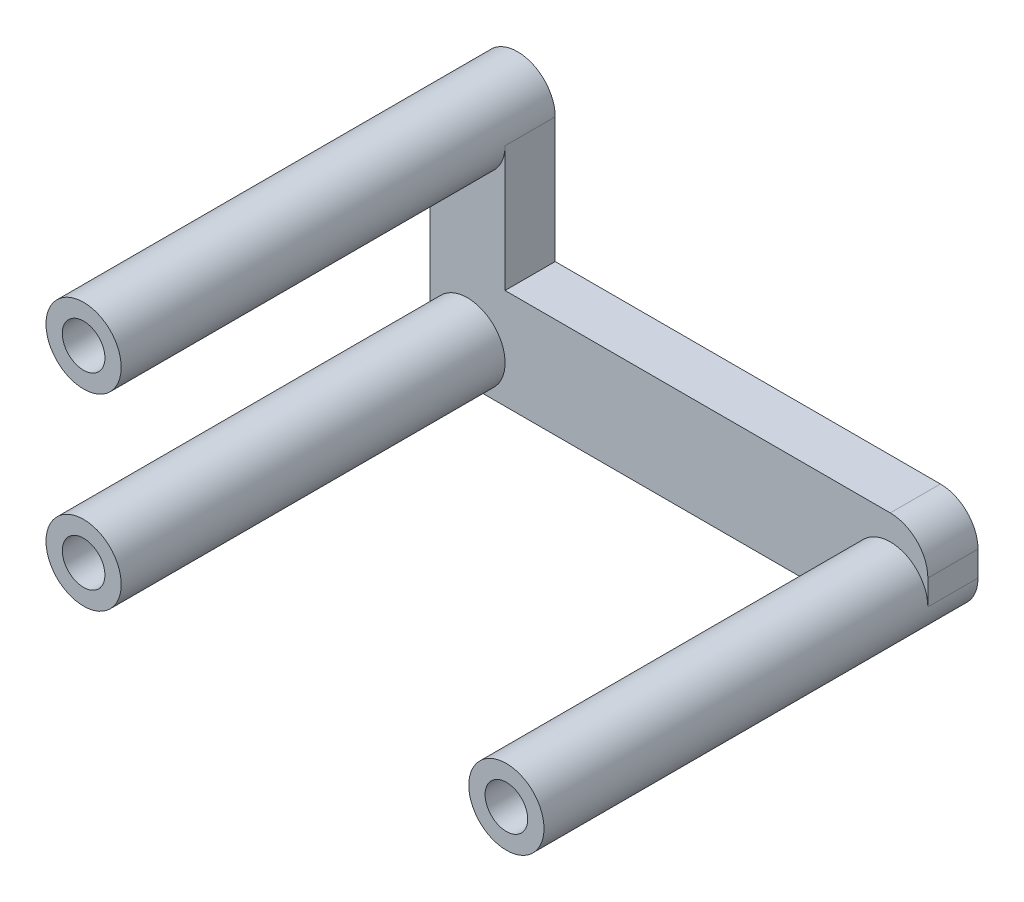
from build123d import *
from build123d.topology import SkipClean

# Parameters (mm, degrees)
SKIZZE1_R                         = 3
AUFSATZ_LINEAR_AUSTRAGEN1_DEPTH   = 4
AUFSATZ_LINEAR_AUSTRAGEN1_2_DEPTH = 4
AUFSATZ_LINEAR_START              = 1
SKIZZE2_W                         = 39.730311682
SKIZZE2_H                         = 6
AUFSATZ_LINEAR_AUSTRAGEN2_DEPTH   = 4
SKIZZE3_R                         = 3
AUFSATZ_LINEAR_AUSTRAGEN3_DEPTH   = 34.6252
SCHNITT_LINEAR_AUSTRAGEN1_DEPTH   = 56.942794256
SKIZZE11_W                        = 6
SKIZZE11_H                        = 15
AUFSATZ_LINEAR_AUSTRAGEN8_DEPTH   = 4
SKIZZE12_R                        = 1.7
SCHNITT_LINEAR_AUSTRAGEN6_DEPTH   = 4
SKIZZE14_W                        = 25.08
SKIZZE14_H                        = 6
SCHNITT_LINEAR_AUSTRAGEN8_DEPTH   = 59.228840184
SKIZZE15_W                        = 33.730311682
SKIZZE15_H                        = 5
AUFSATZ_LINEAR_AUSTRAGEN9_DEPTH   = 4
SKIZZE17_R                        = 1.7
SCHNITT_LINEAR_AUSTRAGEN9_DEPTH   = 2
VERRUNDUNG1_R                     = 3


with BuildPart() as part:
    # Skizze1 → Aufsatz-Linear austragen1 (new body)
    with BuildSketch(Plane.XY):
        with Locations((-15.621, 18.161)):
            Circle(SKIZZE1_R)
    extrude(amount=AUFSATZ_LINEAR_AUSTRAGEN1_DEPTH)



with BuildPart() as body_2:
    # Skizze1 → Aufsatz-Linear austragen1 2 (new body)
    with BuildSketch(Plane.XY):
        with Locations(Location((3.459, 18.161, 0), (0, 0, 180))):
            Circle(SKIZZE1_R)
    extrude(amount=AUFSATZ_LINEAR_AUSTRAGEN1_2_DEPTH)


with BuildPart() as part_1:
    add(part.part)

    add(body_2.part)  # Aufsatz-Linear austragen2 merges body 2
    # Skizze2 → Aufsatz-Linear austragen2 (add)
    with BuildSketch(Plane.XY.offset(AUFSATZ_LINEAR_START)):
        with Locations((-9.868250172, 18.161)):
            Rectangle(SKIZZE2_W, SKIZZE2_H)
    extrude(amount=AUFSATZ_LINEAR_AUSTRAGEN2_DEPTH)

    # Skizze3 → Aufsatz-Linear austragen3 (add)
    with BuildSketch(Plane.XY.offset(1)):
        with Locations(Location((-26.733406013, 18.161, 0), (0, 0, 90))):
            Circle(SKIZZE3_R)
        with Locations(Location((6.996905669, 18.161, 0), (0, 0, 90))):
            Circle(SKIZZE3_R)
        with Locations(Location((-26.733406013, 33.161, 0), (0, 0, 180))):
            Circle(SKIZZE3_R)
    extrude(amount=AUFSATZ_LINEAR_AUSTRAGEN3_DEPTH)


with BuildPart() as aufsatz_linear_austragen3_piece_1:
    # of the separate pieces the step leaves, piece 1, a body of its own (aufsatz_linear_austragen3_pieces)
    add(part_1.part.solids().sort_by_distance((-12.621, 18.161, 0))[0])

    # Skizze5 → Schnitt-Linear austragen1 (cut, through all)
    with SkipClean():  # the faces are left unmerged after this step: merging them gives an invalid solid
        with BuildSketch(Plane.XY.offset(5)):
            with BuildLine():
                Line((-26.733406013, 21.161), (-36.757848336, 21.161))
                Line((-36.757848336, 21.161), (-36.757848336, 15.161))
                Line((-36.757848336, 15.161), (-26.733406013, 15.161))
                ThreePointArc((-26.733406013, 15.161), (-29.733406013, 18.161), (-26.733406013, 21.161))
            make_face()
            with BuildLine():
                Line((17.021347992, 15.161), (6.996905669, 15.161))
                ThreePointArc((6.996905669, 15.161), (9.996905669, 18.161), (6.996905669, 21.161))
                Line((6.996905669, 21.161), (17.021347992, 21.161))
                Line((17.021347992, 21.161), (17.021347992, 15.161))
            make_face()
        extrude(amount=-SCHNITT_LINEAR_AUSTRAGEN1_DEPTH, mode=Mode.SUBTRACT)



with BuildPart() as aufsatz_linear_austragen3_piece_2:
    # of the separate pieces the step leaves, piece 2, a body of its own (aufsatz_linear_austragen3_pieces)
    add(part_1.part.solids().sort_by_distance((-29.733406013, 33.161, 1))[0])


with BuildPart() as aufsatz_linear_austragen3_piece_1_1:
    with SkipClean():  # the faces are left unmerged after this step: merging them gives an invalid solid
        add(aufsatz_linear_austragen3_piece_1.part)

        add(aufsatz_linear_austragen3_piece_2.part)  # Aufsatz-Linear austragen8 merges Aufsatz-Linear austragen3 piece 2
        # Skizze11 → Aufsatz-Linear austragen8 (add)
        with BuildSketch(Plane.XY.offset(5)):
            with Locations((-26.733406013, 25.661)):
                Rectangle(SKIZZE11_W, SKIZZE11_H)
        extrude(amount=-AUFSATZ_LINEAR_AUSTRAGEN8_DEPTH)

    # Skizze12 → Schnitt-Linear austragen6 (cut)
    with SkipClean():  # the faces are left unmerged after this step: merging them gives an invalid solid
        with BuildSketch(Plane.XY.offset(35.6252)):
            with Locations((-26.733406013, 33.161)):
                Circle(SKIZZE12_R)
            with Locations(Location((-26.733406013, 18.161, 0), (0, 0, 180))):
                Circle(SKIZZE12_R)
            with Locations(Location((6.996905669, 18.161, 0), (0, 0, 180))):
                Circle(SKIZZE12_R)
        extrude(amount=-SCHNITT_LINEAR_AUSTRAGEN6_DEPTH, mode=Mode.SUBTRACT)

    # Skizze14 → Schnitt-Linear austragen8 (cut, through all)
    with SkipClean():  # the faces are left unmerged after this step: merging them gives an invalid solid
        with BuildSketch(Plane(origin=(0, 0, 1), x_dir=(-1, 0, 0), z_dir=(0, 0, -1))):
            with Locations((6.081, 18.161)):
                Rectangle(SKIZZE14_W, SKIZZE14_H)
        extrude(amount=SCHNITT_LINEAR_AUSTRAGEN8_DEPTH, mode=Mode.SUBTRACT)

    # Skizze15 → Aufsatz-Linear austragen9 (add)
    with BuildSketch(Plane(origin=(0, 0, 1), x_dir=(-1, 0, 0), z_dir=(0, 0, -1))):
        with Locations((6.868250172, 20.661)):
            Rectangle(SKIZZE15_W, SKIZZE15_H)
    extrude(amount=-AUFSATZ_LINEAR_AUSTRAGEN9_DEPTH)

    # Skizze17 → Schnitt-Linear austragen9 (cut)
    with BuildSketch(Plane(origin=(0, 0, 1), x_dir=(-1, 0, 0), z_dir=(0, 0, -1))):
        with Locations((-5.459, 20.161)):
            Circle(SKIZZE17_R)
        with Locations((15.621, 20.161)):
            Circle(SKIZZE17_R)
    extrude(amount=-SCHNITT_LINEAR_AUSTRAGEN9_DEPTH, mode=Mode.SUBTRACT)

    # Verrundung1
    verrundung1_edges = [aufsatz_linear_austragen3_piece_1_1.edges().sort_by_distance(p)[0] for p in [
        (9.996905669, 23.161, 3),
    ]]
    fillet(verrundung1_edges, radius=VERRUNDUNG1_R)


solid = aufsatz_linear_austragen3_piece_1_1.part
